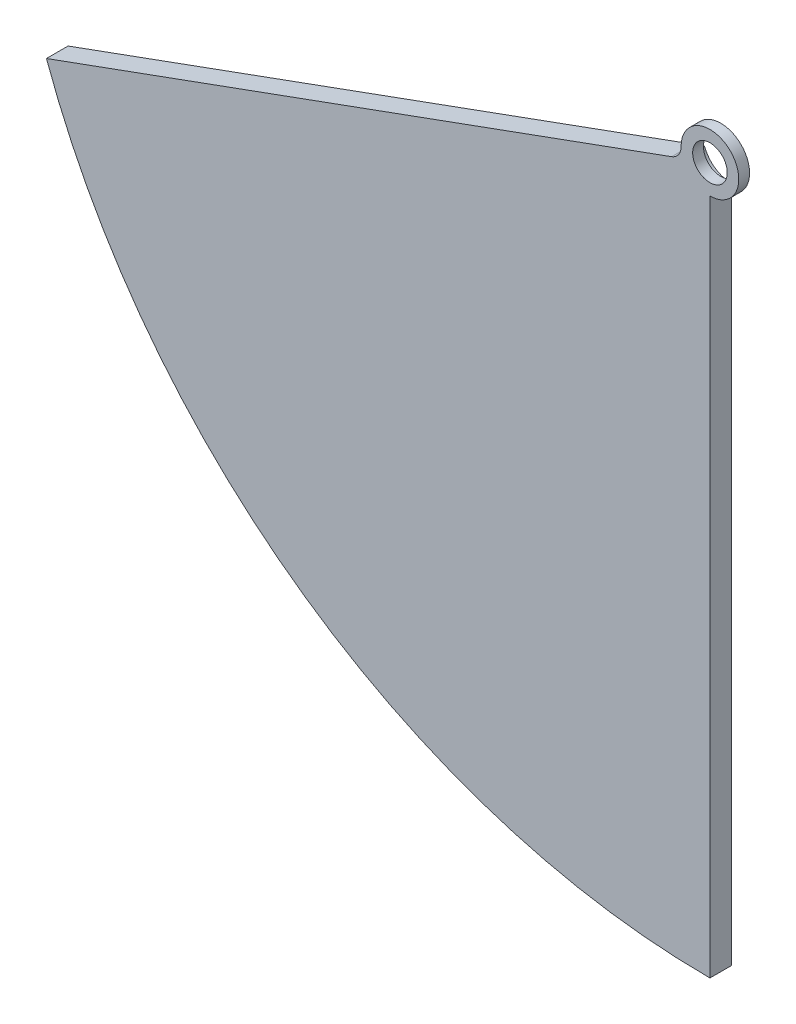
from build123d import *

# Parameters (mm, degrees)
SZKIC1_R                    = 12
DODANIE_WYCI_GNI_CIE1_DEPTH = 15
SZKIC2_R                    = 20
WYTNIJ_WYCI_GNI_CIE1_DEPTH  = 7.5
ZAOKR_GLENIE1_R             = 10


with BuildPart() as part:
    # Szkic1 → Dodanie-wyciągnięcie1 (new body)
    with BuildSketch(Plane.XY):
        with BuildLine():
            Line((0, -20), (0, -490))
            ThreePointArc((0, -490), (-281.052453812, -401.384501702), (-460.449384185, -167.58987023))
            Line((-460.449384185, -167.58987023), (-18.793852416, -6.840402867))
            ThreePointArc((-18.793852416, -6.840402867), (11.471528727, 16.383040886), (0, -20))
        make_face()
        Circle(SZKIC1_R, mode=Mode.SUBTRACT)
    extrude(amount=DODANIE_WYCI_GNI_CIE1_DEPTH)

    # Szkic2 → Wytnij-wyciągnięcie1 (cut)
    with BuildSketch(Plane(origin=(0, 0, 0), x_dir=(-1, 0, 0), z_dir=(0, 0, -1))):
        Circle(SZKIC2_R)
    extrude(amount=-WYTNIJ_WYCI_GNI_CIE1_DEPTH, mode=Mode.SUBTRACT)

    # Zaokrąglenie1
    zaokr_glenie1_edges = [part.edges().sort_by_distance(p)[0] for p in [
        (-18.793852416, -6.840402867, 11.25),
    ]]
    fillet(zaokr_glenie1_edges, radius=ZAOKR_GLENIE1_R)


solid = part.part
